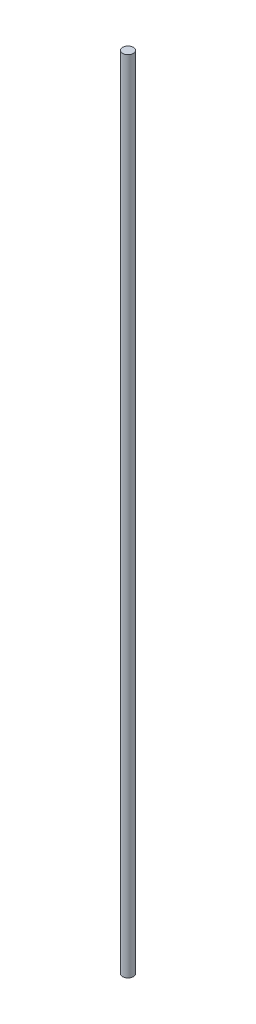
from build123d import *

# Parameters (mm, degrees)
SKETCH2_R           = 10
BOSS_EXTRUDE1_DEPTH = 1500


with BuildPart() as part:
    # Sketch2 → Boss-Extrude1 (new body)
    with BuildSketch(Plane(origin=(0, 0, 0), x_dir=(1, 0, 0), z_dir=(0, 1, 0))):
        Circle(SKETCH2_R)
    extrude(amount=BOSS_EXTRUDE1_DEPTH)


solid = part.part
